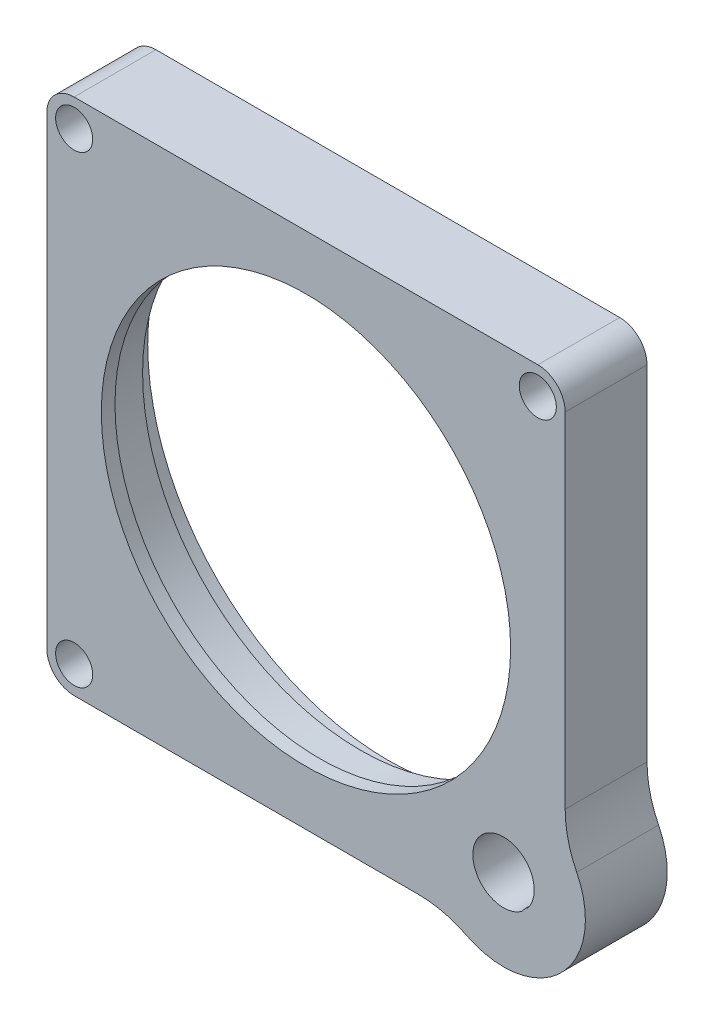
from build123d import *

# Parameters (mm, degrees)
SKETCH1_R                = 2.159
SKETCH1_R_2              = 28.5115
BOSS_EXTRUDE1_DEPTH      = 9.525
SKETCH1_4_R              = 28.5115
SKETCH1_4_R_2            = 23.8125
FLUSH_BEZEL_DEPTH        = 9.525
SKETCH1_5_R              = 28.5115
SKETCH1_5_R_2            = 23.8125
BOSS_EXTRUDE4_DEPTH      = 6.35
SKETCH2_R                = 25.3365
CUT_EXTRUDE1_DEPTH       = 7.35
CUT_EXTRUDE1_DEPTH_BACK  = 9.525
SKETCH3_R                = 28.5115
CUT_EXTRUDE2_DEPTH       = 7.35
SKETCH4_R                = 25.3365
SKETCH4_R_2              = 23.8125
BOSS_EXTRUDE7_DEPTH      = 1.5875
M6_CLEARANCE_HOLE1_D     = 7.14248
M6_CLEARANCE_HOLE1_DEPTH = 9.525
SKETCH8_R                = 2.159
BOSS_EXTRUDE8_DEPTH      = 9.525
SKETCH9_R                = 2.159
CUT_EXTRUDE3_DEPTH       = 10.525
SKETCH10_R               = 27.94
CUT_EXTRUDE4_DEPTH       = 3.2004
BOSS_EXTRUDE10_DEPTH     = 9.525
SKETCH12_R               = 7.9375
CUT_EXTRUDE5_DEPTH       = 3.2004
FILLET6_R                = 12.7
FILLET7_R                = 6.35
HOLE1_AT_2_COUNT         = 2
HOLE1_AT_2_PITCH         = 50.811879198
SKETCH18_W               = 1.5
SKETCH18_H               = 3.81
HOLE2_AT_2_COUNT         = 2
HOLE2_AT_2_PITCH         = 50.811879198


with BuildPart() as part:
    # Sketch1 → Boss-Extrude1 (new body)
    with BuildSketch(Plane.XY):
        with BuildLine():
            ThreePointArc((26.9875, -30.1625), (29.23256403, -29.23256403), (30.1625, -26.9875))
            Line((30.1625, -26.9875), (30.1625, 26.9875))
            ThreePointArc((30.1625, 26.9875), (29.23256403, 29.23256403), (26.9875, 30.1625))
            Line((26.9875, 30.1625), (-26.9875, 30.1625))
            ThreePointArc((-26.9875, 30.1625), (-29.23256403, 29.23256403), (-30.1625, 26.9875))
            Line((-30.1625, 26.9875), (-30.1625, -26.9875))
            ThreePointArc((-30.1625, -26.9875), (-29.23256403, -29.23256403), (-26.9875, -30.1625))
            Line((-26.9875, -30.1625), (26.9875, -30.1625))
        make_face()
        with Locations((26.9748, -26.9748)):
            Circle(SKETCH1_R, mode=Mode.SUBTRACT)
        with Locations((-26.9748, 26.9748)):
            Circle(SKETCH1_R, mode=Mode.SUBTRACT)
        Circle(SKETCH1_R_2, mode=Mode.SUBTRACT)
        with Locations((26.9748, 26.9748)):
            Circle(SKETCH1_R, mode=Mode.SUBTRACT)
    extrude(amount=BOSS_EXTRUDE1_DEPTH)

    # Sketch1_4 → Flush Bezel (add)
    with BuildSketch(Plane.XY):
        Circle(SKETCH1_4_R)
        Circle(SKETCH1_4_R_2, mode=Mode.SUBTRACT)
    extrude(amount=FLUSH_BEZEL_DEPTH)

    # Sketch1_5 → Boss-Extrude4 (add)
    with BuildSketch(Plane.XY):
        Circle(SKETCH1_5_R)
        Circle(SKETCH1_5_R_2, mode=Mode.SUBTRACT)
    extrude(amount=-BOSS_EXTRUDE4_DEPTH)

    # Sketch2 → Cut-Extrude1 (cut, two sides)
    with BuildSketch(Plane(origin=(0, 0, 0), x_dir=(-1, 0, 0), z_dir=(0, 0, -1))) as cut_extrude1_sk:
        Circle(SKETCH2_R)
    extrude(amount=CUT_EXTRUDE1_DEPTH, mode=Mode.SUBTRACT)
    extrude(cut_extrude1_sk.sketch, amount=-CUT_EXTRUDE1_DEPTH_BACK, mode=Mode.SUBTRACT)

    # Sketch3 → Cut-Extrude2 (cut, through all)
    with BuildSketch(Plane(origin=(0, 0, 0), x_dir=(-1, 0, 0), z_dir=(0, 0, -1))):
        Circle(SKETCH3_R)
    extrude(amount=CUT_EXTRUDE2_DEPTH, mode=Mode.SUBTRACT)

    # Sketch4 → Boss-Extrude7 (add)
    with BuildSketch(Plane.XY.offset(9.525)):
        Circle(SKETCH4_R)
        Circle(SKETCH4_R_2, mode=Mode.SUBTRACT)
    extrude(amount=-BOSS_EXTRUDE7_DEPTH)

    # M6 Clearance Hole1
    with Locations(Plane.XY.offset(9.525)):
        with Locations((22.98945567, -22.98945567)):
            Hole(M6_CLEARANCE_HOLE1_D / 2, depth=M6_CLEARANCE_HOLE1_DEPTH)

    # Sketch8 → Boss-Extrude8 (add, through all)
    with BuildSketch(Plane.XY.offset(9.525)):
        with Locations((26.9748, -26.9748)):
            Circle(SKETCH8_R)
    extrude(amount=-BOSS_EXTRUDE8_DEPTH)

    # Sketch9 → Cut-Extrude3 (cut, through all)
    with BuildSketch(Plane.XY.offset(9.525)):
        with Locations((-26.9748, -26.9748)):
            Circle(SKETCH9_R)
    extrude(amount=-CUT_EXTRUDE3_DEPTH, mode=Mode.SUBTRACT)

    # Sketch10 → Cut-Extrude4 (cut)
    with BuildSketch(Plane(origin=(0, 0, 0), x_dir=(-1, 0, 0), z_dir=(0, 0, -1))):
        Circle(SKETCH10_R)
    extrude(amount=-CUT_EXTRUDE4_DEPTH, mode=Mode.SUBTRACT)

    # Sketch13 → Boss-Extrude10 (add)
    with BuildSketch(Plane(origin=(0, 0, 0), x_dir=(-1, 0, 0), z_dir=(0, 0, -1))):
        with BuildLine():
            Line((-16.722633506, -30.1625), (-26.9875, -30.1625))
            ThreePointArc((-26.9875, -30.1625), (-29.23256403, -29.23256403), (-30.1625, -26.9875))
            Line((-30.1625, -26.9875), (-30.1625, -16.722633506))
            ThreePointArc((-30.1625, -16.722633506), (-29.724647761, -29.724647761), (-16.722633506, -30.1625))
        make_face()
    extrude(amount=-BOSS_EXTRUDE10_DEPTH)

    # Sketch12 → Cut-Extrude5 (cut)
    with BuildSketch(Plane(origin=(0, 0, 0), x_dir=(-1, 0, 0), z_dir=(0, 0, -1))):
        with Locations((-22.98945567, -22.98945567)):
            Circle(SKETCH12_R)
    extrude(amount=-CUT_EXTRUDE5_DEPTH, mode=Mode.SUBTRACT)

    # Fillet6
    fillet6_edges = [part.edges().sort_by_distance(p)[0] for p in [
        (30.1625, -16.722633506, 4.7625),
        (16.722633506, -30.1625, 4.7625),
    ]]
    fillet(fillet6_edges, radius=FILLET6_R)

    # Fillet7
    fillet7_edges = [part.edges().sort_by_distance(p)[0] for p in [
        (23.527276854, -15.070197206, 1.6002),
        (15.070197206, -23.527276854, 1.6002),
    ]]
    fillet(fillet7_edges, radius=FILLET7_R)

    # Sketch14 → Hole1 (revolve, cut)
    with BuildSketch(Plane(origin=(-25.405939599, 16.116198413, 0), x_dir=(0, 1, 0), z_dir=(1, 0, 0))):
        Polygon((0, 0), (0, 2.921), (1.4986, 2.921), (1.6383, 0), align=None)
    hole1 = revolve(axis=Axis((-25.405939599, 16.116198413, 110), (0, 0, -1)), mode=Mode.SUBTRACT)

    # Hole1 at 2: Hole1 ×2
    with Locations(*[(i * HOLE1_AT_2_PITCH, 0, 0) for i in range(1, HOLE1_AT_2_COUNT)]):
        add(hole1, mode=Mode.SUBTRACT)

    # Sketch18 → Hole2 (revolve, cut)
    with BuildSketch(Plane(origin=(25.405939599, 16.116198413, 2.921), x_dir=(0, 1, 0), z_dir=(1, 0, 0))):
        with Locations((0.75, 1.905)):
            Rectangle(SKETCH18_W, SKETCH18_H)
    hole2 = revolve(axis=Axis((25.405939599, 16.116198413, 112.921), (0, 0, -1)), mode=Mode.SUBTRACT)

    # Hole2 at 2: Hole2 ×2
    with Locations(*[(-i * HOLE2_AT_2_PITCH, 0, 0) for i in range(1, HOLE2_AT_2_COUNT)]):
        add(hole2, mode=Mode.SUBTRACT)


solid = part.part
